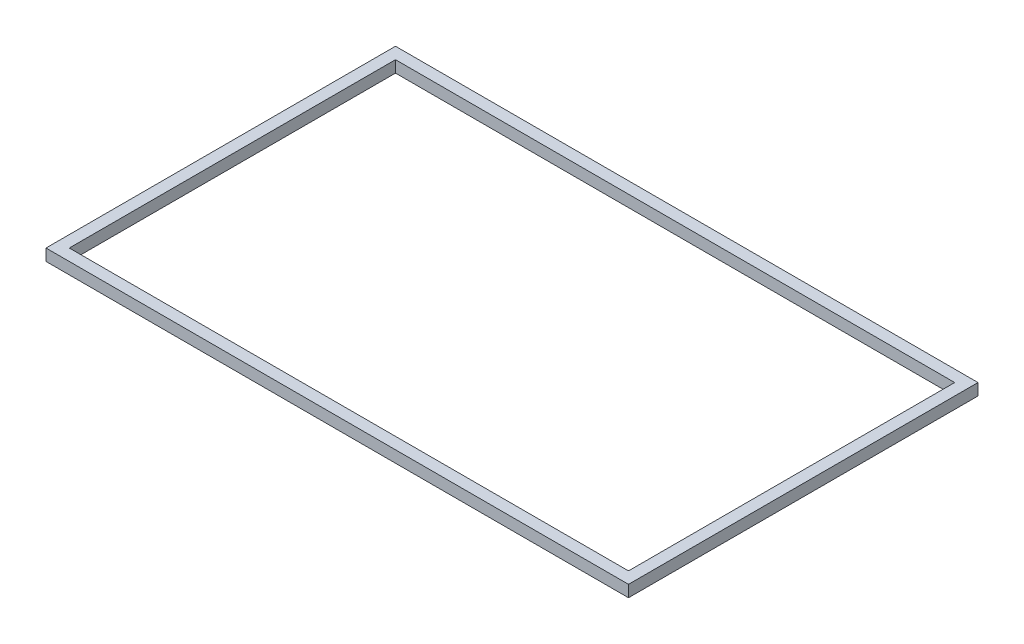
from build123d import *

# Parameters (mm, degrees)
SKETCH1_W                                         = 250
SKETCH1_H                                         = 150
BOSS_EXTRUDE1_DEPTH                               = 5
CUT_EXTRUDE1_DEPTH                                = 5
CSK_FOR_8_FLAT_HEAD_MACHINE_SCREW_100_D           = 4.4958
CSK_FOR_8_FLAT_HEAD_MACHINE_SCREW_100_CSINK_D     = 8.4328
CSK_FOR_8_FLAT_HEAD_MACHINE_SCREW_100_CSINK_ANGLE = 100
SKETCH4_W                                         = 10
SKETCH4_H                                         = 12.954582158
CUT_EXTRUDE2_DEPTH                                = 10


with BuildPart() as part:
    # Sketch1 → Boss-Extrude1 (new body)
    with BuildSketch(Plane(origin=(0, 0, 0), x_dir=(1, 0, 0), z_dir=(0, 1, 0))):
        with Locations((125, 75)):
            Rectangle(SKETCH1_W, SKETCH1_H)
    extrude(amount=BOSS_EXTRUDE1_DEPTH)

    # Sketch2 → Cut-Extrude1 (cut)
    with BuildSketch(Plane(origin=(0, 5, 0), x_dir=(1, 0, 0), z_dir=(0, 1, 0))):
        Polygon((5, 5), (245, 5), (245, 68.522708921), (235, 68.522708921), (235, 81.477291079), (245, 81.477291079), (245, 145), (5, 145), align=None)
    extrude(amount=-CUT_EXTRUDE1_DEPTH, mode=Mode.SUBTRACT)

    # CSK for #8 Flat Head Machine Screw (100)1 (through all)
    with Locations(Plane(origin=(240.110859841, 5, -75.135992341), x_dir=(0, 0, 1), z_dir=(0, 1, 0))):
        with Locations((0, 0)):
            CounterSinkHole(CSK_FOR_8_FLAT_HEAD_MACHINE_SCREW_100_D / 2, CSK_FOR_8_FLAT_HEAD_MACHINE_SCREW_100_CSINK_D / 2, counter_sink_angle=CSK_FOR_8_FLAT_HEAD_MACHINE_SCREW_100_CSINK_ANGLE)

    # Sketch4 → Cut-Extrude2 (cut)
    with BuildSketch(Plane(origin=(0, 5, 0), x_dir=(1, 0, 0), z_dir=(0, 1, 0))):
        with Locations((240, 75)):
            Rectangle(SKETCH4_W, SKETCH4_H)
    extrude(amount=-CUT_EXTRUDE2_DEPTH, mode=Mode.SUBTRACT)


solid = part.part
